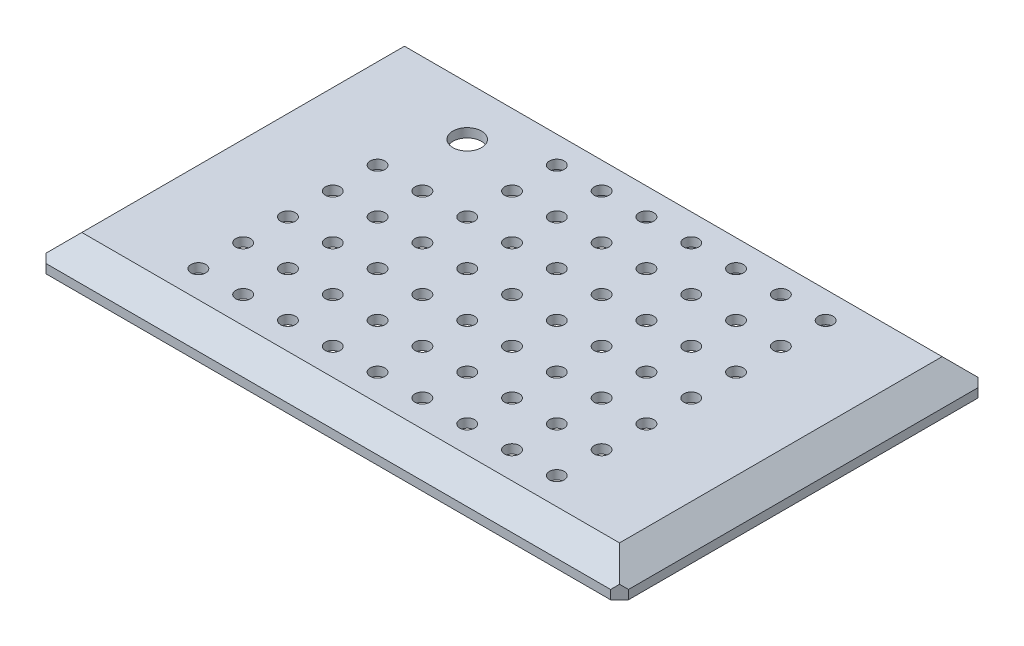
from build123d import *

# Parameters (mm, degrees)
SKETCH1_W           = 130
SKETCH1_H           = 82
BOSS_EXTRUDE1_DEPTH = 2
SKETCH3_W           = 120
SKETCH3_H           = 72
SKETCH2_W           = 130
SKETCH2_H           = 82
CHAMFER2_SIZE       = 2
SKETCH4_W           = 8
SKETCH4_H           = 10
BOSS_EXTRUDE2_DEPTH = 7
SKETCH5_R           = 2.05
CUT_EXTRUDE1_DEPTH  = 123.9000001
SKETCH6_W           = 97.8
SKETCH6_H           = 70
CUT_EXTRUDE2_DEPTH  = 5
SKETCH7_R           = 1.65
CUT_EXTRUDE3_DEPTH  = 3.0000001
SKETCH8_R           = 3.2
CUT_EXTRUDE4_DEPTH  = 15
SKETCH9_R           = 1.65
BOSS_EXTRUDE3_DEPTH = 2


with BuildPart() as part:
    # Sketch1 → Boss-Extrude1 (new body)
    with BuildSketch(Plane(origin=(0, 0, 0), x_dir=(1, 0, 0), z_dir=(0, 1, 0))):
        Rectangle(SKETCH1_W, SKETCH1_H)
    extrude(amount=BOSS_EXTRUDE1_DEPTH)

    # Sketch3 → Loft1 section 0
    with BuildSketch(Plane(origin=(0, 7, 0), x_dir=(1, 0, 0), z_dir=(0, 1, 0))):
        Rectangle(SKETCH3_W, SKETCH3_H)
    # Sketch2 → Loft1 section 1
    with BuildSketch(Plane(origin=(0, 2, 0), x_dir=(1, 0, 0), z_dir=(0, 1, 0))):
        Rectangle(SKETCH2_W, SKETCH2_H)
    loft()

    # Chamfer2
    chamfer2_edges = [part.edges().sort_by_distance(p)[0] for p in [
        (65, 1, 41),
        (-65, 1, 41),
        (-65, 1, -41),
        (65, 1, -41),
    ]]
    chamfer(chamfer2_edges, length=CHAMFER2_SIZE)

    # Sketch4 → Boss-Extrude2 (add)
    with BuildSketch(Plane.XZ):
        with Locations((-53.9, 20)):
            Rectangle(SKETCH4_W, SKETCH4_H)
        with Locations((-53.9, -20)):
            Rectangle(SKETCH4_W, SKETCH4_H)
        with Locations((53.9, -20)):
            Rectangle(SKETCH4_W, SKETCH4_H)
        with Locations((53.9, 20)):
            Rectangle(SKETCH4_W, SKETCH4_H)
    extrude(amount=BOSS_EXTRUDE2_DEPTH)

    # Sketch5 → Cut-Extrude1 (cut, through all)
    with BuildSketch(Plane.ZY.offset(57.9)):
        with Locations((-20, -3.5)):
            Circle(SKETCH5_R)
        with Locations((20, -3.5)):
            Circle(SKETCH5_R)
    extrude(amount=-CUT_EXTRUDE1_DEPTH, mode=Mode.SUBTRACT)

    # Sketch6 → Cut-Extrude2 (cut)
    with BuildSketch(Plane.XZ):
        Rectangle(SKETCH6_W, SKETCH6_H)
    extrude(amount=-CUT_EXTRUDE2_DEPTH, mode=Mode.SUBTRACT)

    # Sketch7 → Cut-Extrude3 (cut, through all)
    with BuildSketch(Plane.XZ.offset(-5)):
        Circle(SKETCH7_R)
        with Locations((10, 0)):
            Circle(SKETCH7_R)
        with Locations((20, 0)):
            Circle(SKETCH7_R)
        with Locations((30, 0)):
            Circle(SKETCH7_R)
        with Locations((40, 0)):
            Circle(SKETCH7_R)
        with Locations((10, 10)):
            Circle(SKETCH7_R)
        with Locations((20, 10)):
            Circle(SKETCH7_R)
        with Locations((30, 10)):
            Circle(SKETCH7_R)
        with Locations((40, 10)):
            Circle(SKETCH7_R)
        with Locations((10, 20)):
            Circle(SKETCH7_R)
        with Locations((20, 20)):
            Circle(SKETCH7_R)
        with Locations((30, 20)):
            Circle(SKETCH7_R)
        with Locations((40, 20)):
            Circle(SKETCH7_R)
        with Locations((10, 30)):
            Circle(SKETCH7_R)
        with Locations((20, 30)):
            Circle(SKETCH7_R)
        with Locations((30, 30)):
            Circle(SKETCH7_R)
        with Locations((40, 30)):
            Circle(SKETCH7_R)
        with Locations((0, 10)):
            Circle(SKETCH7_R)
        with Locations((0, 20)):
            Circle(SKETCH7_R)
        with Locations((0, 30)):
            Circle(SKETCH7_R)
        with Locations((-40, 30)):
            Circle(SKETCH7_R)
        with Locations((-30, 30)):
            Circle(SKETCH7_R)
        with Locations((-20, 30)):
            Circle(SKETCH7_R)
        with Locations((-10, 30)):
            Circle(SKETCH7_R)
        with Locations((-40, 20)):
            Circle(SKETCH7_R)
        with Locations((-30, 20)):
            Circle(SKETCH7_R)
        with Locations((-20, 20)):
            Circle(SKETCH7_R)
        with Locations((-10, 20)):
            Circle(SKETCH7_R)
        with Locations((-40, 10)):
            Circle(SKETCH7_R)
        with Locations((-30, 10)):
            Circle(SKETCH7_R)
        with Locations((-20, 10)):
            Circle(SKETCH7_R)
        with Locations((-10, 10)):
            Circle(SKETCH7_R)
        with Locations((-40, 0)):
            Circle(SKETCH7_R)
        with Locations((-30, 0)):
            Circle(SKETCH7_R)
        with Locations((-20, 0)):
            Circle(SKETCH7_R)
        with Locations((-10, 0)):
            Circle(SKETCH7_R)
        with Locations((-10, -10)):
            Circle(SKETCH7_R)
        with Locations((-20, -10)):
            Circle(SKETCH7_R)
        with Locations((-30, -10)):
            Circle(SKETCH7_R)
        with Locations((-40, -10)):
            Circle(SKETCH7_R)
        with Locations((-10, -20)):
            Circle(SKETCH7_R)
        with Locations((-20, -20)):
            Circle(SKETCH7_R)
        with Locations((-30, -20)):
            Circle(SKETCH7_R)
        with Locations((-40, -20)):
            Circle(SKETCH7_R)
        with Locations((-10, -30)):
            Circle(SKETCH7_R)
        with Locations((-20, -30)):
            Circle(SKETCH7_R)
        with Locations((-30, -30)):
            Circle(SKETCH7_R)
        with Locations((-40, -30)):
            Circle(SKETCH7_R)
        with Locations((0, -30)):
            Circle(SKETCH7_R)
        with Locations((0, -20)):
            Circle(SKETCH7_R)
        with Locations((0, -10)):
            Circle(SKETCH7_R)
        with Locations((40, -30)):
            Circle(SKETCH7_R)
        with Locations((30, -30)):
            Circle(SKETCH7_R)
        with Locations((20, -30)):
            Circle(SKETCH7_R)
        with Locations((10, -30)):
            Circle(SKETCH7_R)
        with Locations((40, -20)):
            Circle(SKETCH7_R)
        with Locations((30, -20)):
            Circle(SKETCH7_R)
        with Locations((20, -20)):
            Circle(SKETCH7_R)
        with Locations((10, -20)):
            Circle(SKETCH7_R)
        with Locations((40, -10)):
            Circle(SKETCH7_R)
        with Locations((30, -10)):
            Circle(SKETCH7_R)
        with Locations((20, -10)):
            Circle(SKETCH7_R)
        with Locations((10, -10)):
            Circle(SKETCH7_R)
    extrude(amount=-CUT_EXTRUDE3_DEPTH, mode=Mode.SUBTRACT)

    # Sketch8 → Cut-Extrude4 (cut, through all)
    with BuildSketch(Plane(origin=(0, 7, 0), x_dir=(1, 0, 0), z_dir=(0, 1, 0))):
        with Locations((-35, 25)):
            Circle(SKETCH8_R)
    extrude(amount=-CUT_EXTRUDE4_DEPTH, mode=Mode.SUBTRACT)

    # Sketch9 → Boss-Extrude3 (add)
    with BuildSketch(Plane(origin=(0, 7, 0), x_dir=(1, 0, 0), z_dir=(0, 1, 0))):
        with Locations((-30, 20)):
            Circle(SKETCH9_R)
        with Locations((-40, 20)):
            Circle(SKETCH9_R)
        with Locations((-40, 30)):
            Circle(SKETCH9_R)
        with Locations((-30, 30)):
            Circle(SKETCH9_R)
    extrude(amount=-BOSS_EXTRUDE3_DEPTH)


solid = part.part
